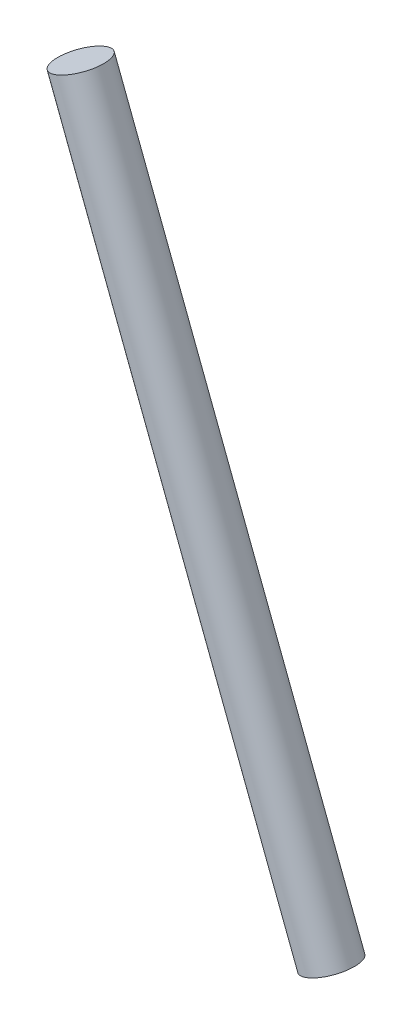
from build123d import *


with BuildPart() as part:
    # Sketch1 → Revolve1 (revolve)
    with BuildSketch(Plane.XY):
        Polygon((536.075927907, 722.923963252), (613.700655846, 519.609574418), (606.581860379, 516.891643018), (528.957132439, 720.206031852), align=None)
    revolve(axis=Axis((536.075927907, 722.923963252, 0), (0.356683911, -0.934225127, 0)))


solid = part.part
